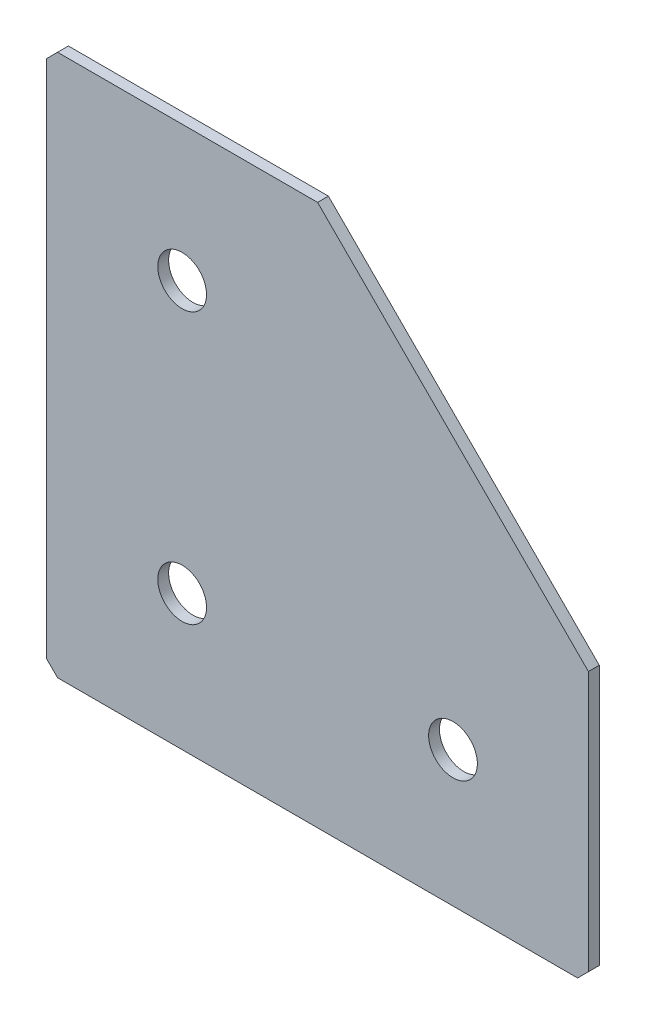
from build123d import *

# Parameters (mm, degrees)
EXTRUDE_1_DEPTH   = 2
HOLE_WIZARD_M81_D = 9
CHAMFER_1_SIZE    = 2


with BuildPart() as part:
    # Эскиз1 → Бобышка-Вытянуть1 (new body)
    with BuildSketch(Plane(origin=(0, 0, 0), x_dir=(1, 0, 0), z_dir=(0, 0, -1))):
        Polygon((0, 0), (0, 100), (100, 100), (100, 50), (50, 0), align=None)
    extrude(amount=EXTRUDE_1_DEPTH)

    # Отверстие с зазором M81 (through all)
    with Locations(Plane(origin=(0, 0, -2), x_dir=(1, 0, 0), z_dir=(0, 0, -1))):
        with Locations((25, 75), (25, 25), (75, 75)):
            Hole(HOLE_WIZARD_M81_D / 2)

    # Фаска1
    chamfer_1_edges = [part.edges().sort_by_distance(p)[0] for p in [
        (0, 0, -1),
        (0, -100, -1),
        (100, -100, -1),
    ]]
    chamfer(chamfer_1_edges, length=CHAMFER_1_SIZE)


solid = part.part
